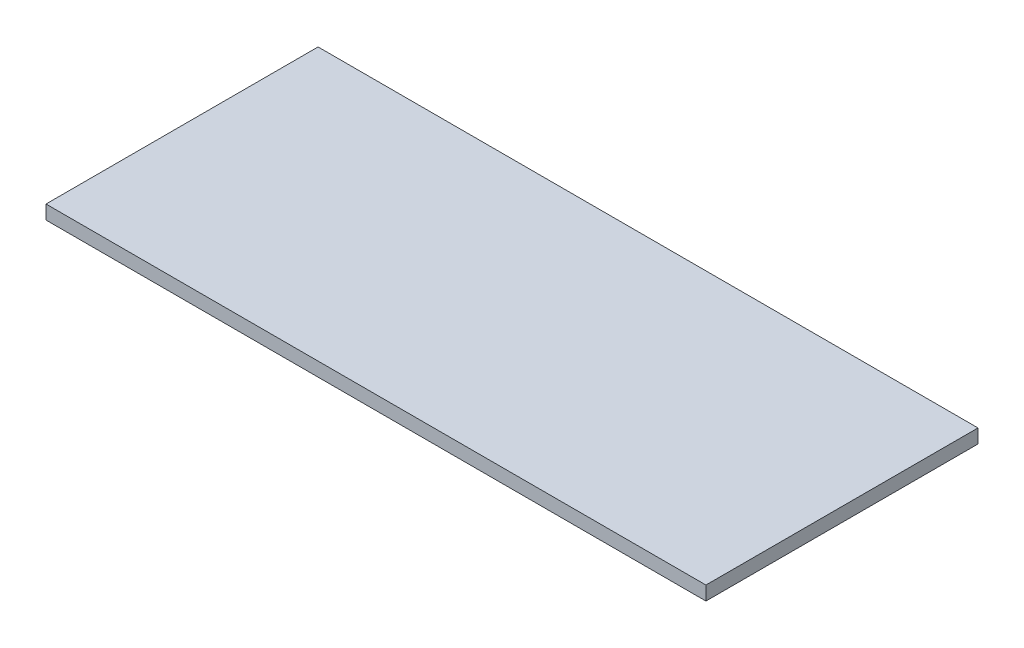
from build123d import *

# Parameters (mm, degrees)
SKETCH2_W           = 677.696585676
SKETCH2_H           = 279.4
BOSS_EXTRUDE2_DEPTH = 14.2875


with BuildPart() as part:
    # Sketch2 → Boss-Extrude2 (new body)
    with BuildSketch(Plane(origin=(0, 0, 0), x_dir=(1, 0, 0), z_dir=(0, 1, 0))):
        with Locations((-497.754542735, -305.557235018)):
            Rectangle(SKETCH2_W, SKETCH2_H)
    extrude(amount=BOSS_EXTRUDE2_DEPTH)


solid = part.part
